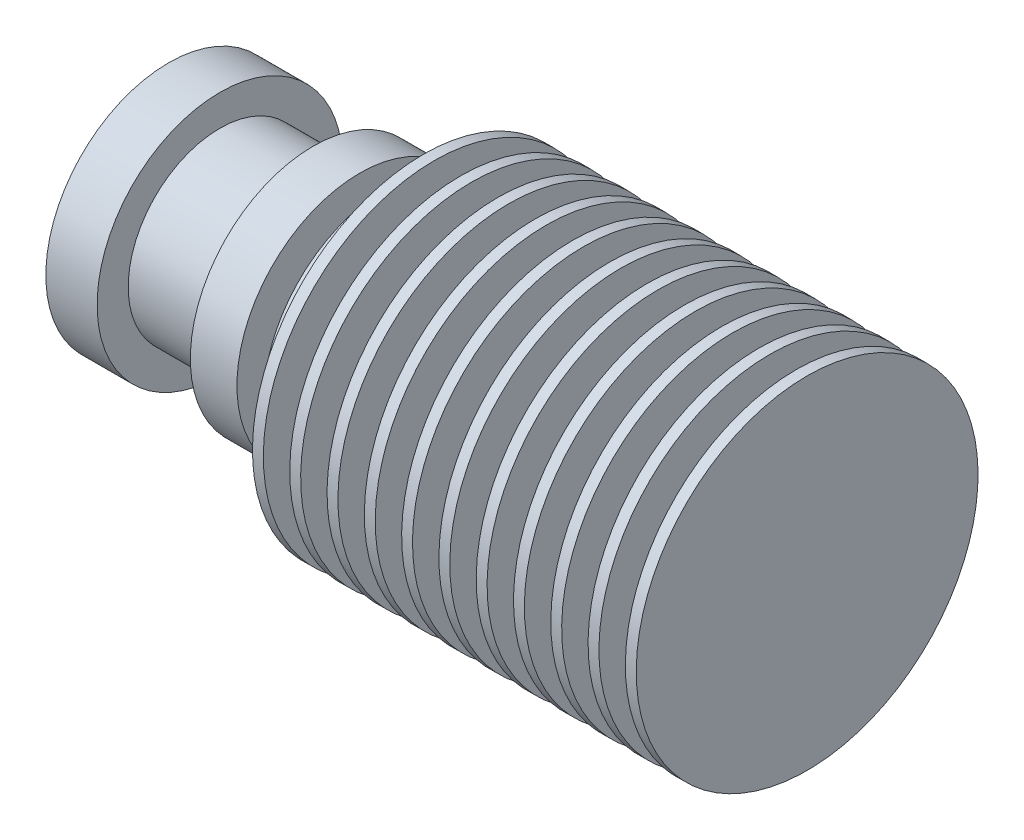
from build123d import *


with BuildPart() as part:
    # Esboço1 → Revolução1 (revolve)
    with BuildSketch(Plane.XY):
        Polygon((-27.999975, 5), (-27.999975, 16), (-28.699975, 16), (-28.699975, 10), (-30.399975, 10), (-30.399975, 16), (-31.099975, 16), (-31.099975, 10), (-32.799975, 10), (-32.799975, 16), (-33.499975, 16), (-33.499975, 10), (-35.199975, 10), (-35.199975, 16), (-35.899975, 16), (-35.899975, 10), (-37.599975, 10), (-37.599975, 16), (-38.299975, 16), (-38.299975, 10), (-39.999975, 10), (-39.999975, 16), (-40.699975, 16), (-40.699975, 10), (-42.399975, 10), (-42.399975, 16), (-43.099975, 16), (-43.099975, 10), (-44.799975, 10), (-44.799975, 16), (-45.499975, 16), (-45.499975, 10), (-47.199975, 10), (-47.199975, 16), (-47.899975, 16), (-47.899975, 10), (-49.599975, 10), (-49.599975, 16), (-50.299975, 16), (-50.299975, 10), (-51.999975, 10), (-51.999975, 16), (-52.699975, 16), (-52.699975, 10), (-54.399975, 10), (-54.399975, 12.9), (-55.099975, 12.9), (-55.099975, 10), (-56.799975, 10), (-56.799975, 12.9), (-59.799975, 12.9), (-59.799975, 10.9), (-65.799975, 10.9), (-65.799975, 12.9), (-69.099975, 12.9), (-69.099975, 5), align=None)
    revolve(axis=Axis((-27.999975, 5, 0), (-1, 0, 0)))


solid = part.part
